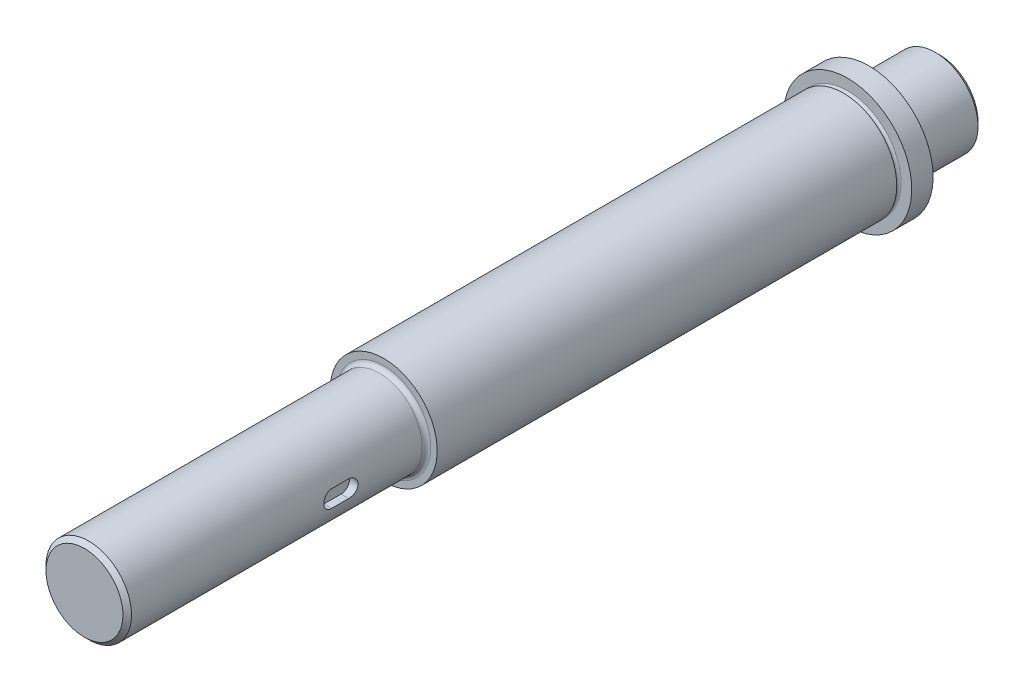
from build123d import *

# Parameters (mm, degrees)
FILLET1_R          = 1
FILLET2_R          = 3
CHAMFER1_SIZE      = 1
CUT_EXTRUDE2_START = 10
CUT_EXTRUDE2_DEPTH = 2
CHAMFER2_SIZE      = 1


with BuildPart() as part:
    # Sketch1 → Revolve1 (revolve)
    with BuildSketch(Plane(origin=(0, 0, 0), x_dir=(0, 0, -1), z_dir=(1, 0, 0))):
        with BuildLine():
            Line((0, 0), (0, -10))
            Line((0, -10), (-16.5, -10))
            Line((-16.5, -10), (-16.5, -15))
            Line((-16.5, -15), (-21.5, -15))
            Line((-21.5, -15), (-21.5, -12.5))
            ThreePointArc((-21.5, -12.5), (-22, -12), (-22.5, -12.5))
            Line((-22.5, -12.5), (-130, -12.5))
            Line((-130, -12.5), (-130, -10))
            Line((-130, -10), (-200, -10))
            Line((-200, -10), (-200, 0))
            Line((-200, 0), (0, 0))
        make_face()
    revolve(axis=Axis((0, 0, 0), (0, 0, 1)))

    # Fillet1
    fillet1_edges = [part.edges().sort_by_distance(p)[0] for p in [
        (0, 10, 130),
    ]]
    fillet(fillet1_edges, radius=FILLET1_R)

    # Fillet2
    fillet2_edges = [part.edges().sort_by_distance(p)[0] for p in [
        (0, 10, 16.5),
    ]]
    fillet(fillet2_edges, radius=FILLET2_R)

    # Chamfer1
    chamfer1_edges = [part.edges().sort_by_distance(p)[0] for p in [
        (0, 10, 200),
    ]]
    chamfer(chamfer1_edges, length=CHAMFER1_SIZE)

    # Sketch2 → Cut-Extrude2 (cut)
    with BuildSketch(Plane(origin=(0, 0, 0), x_dir=(0, 0, -1), z_dir=(1, 0, 0)).offset(CUT_EXTRUDE2_START)):
        with BuildLine():
            Line((-148, -2), (-152, -2))
            ThreePointArc((-152, -2), (-154, 0), (-152, 2))
            Line((-152, 2), (-148, 2))
            ThreePointArc((-148, 2), (-146, 0), (-148, -2))
        make_face()
    extrude(amount=-CUT_EXTRUDE2_DEPTH, mode=Mode.SUBTRACT)

    # Chamfer2
    chamfer2_edges = [part.edges().sort_by_distance(p)[0] for p in [
        (0, 10, 0),
    ]]
    chamfer(chamfer2_edges, length=CHAMFER2_SIZE)


solid = part.part
